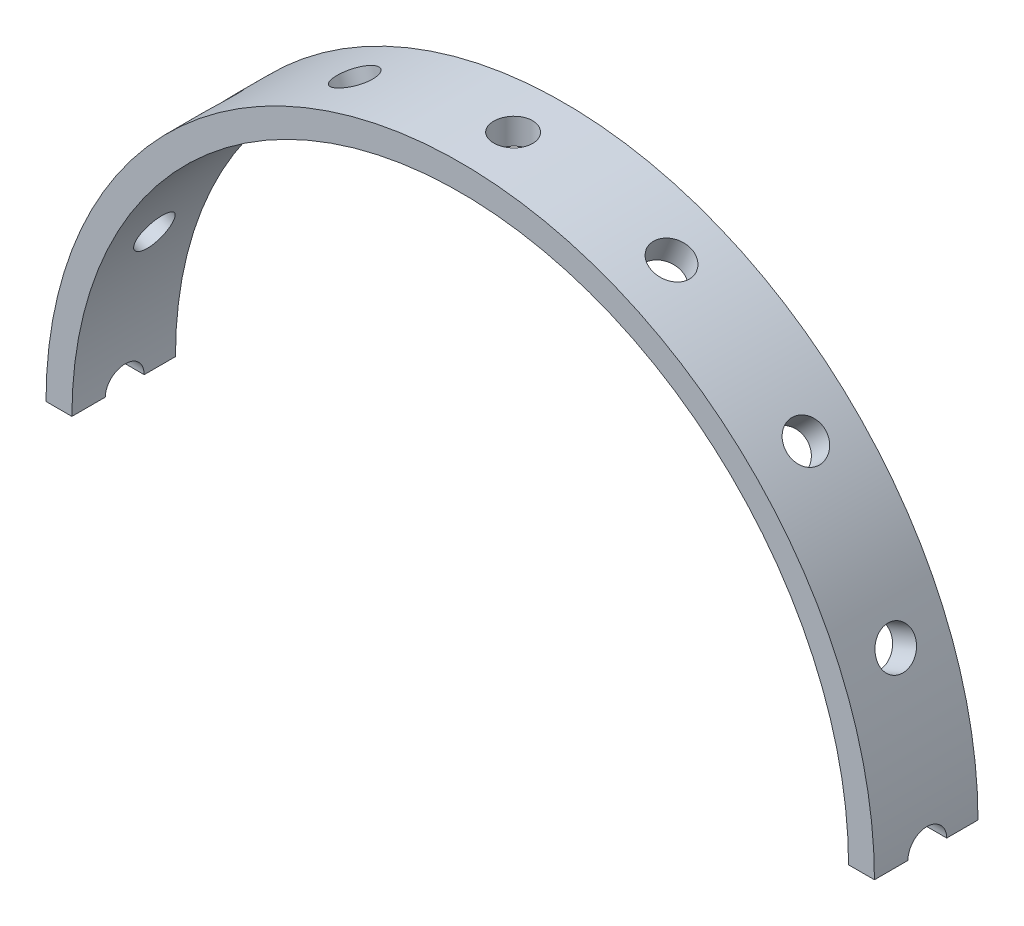
from build123d import *

# Parameters (mm, degrees)
SKETCH_1_R               = 16
SKETCH_1_R_2             = 15
EXTRUDE_1_DEPTH          = 4
SKETCH_2_R               = 0.75
CUT_EXTRUDE_1_DEPTH      = 17
PATTERN_CIRCULAR_1_COUNT = 16
SKETCH_3_W               = 36.79853237
SKETCH_3_H               = 11.94610836
CUT_EXTRUDE_2_DEPTH      = 17.0000001


with BuildPart() as part:
    # ｽｹｯﾁ1 → ﾎﾞｽ - 押し出し1 (new body)
    with BuildSketch(Plane.XY):
        Circle(SKETCH_1_R)
        Circle(SKETCH_1_R_2, mode=Mode.SUBTRACT)
    extrude(amount=EXTRUDE_1_DEPTH)

    # ｽｹｯﾁ2 → ｶｯﾄ - 押し出し1 (cut, through all)
    with BuildSketch(Plane(origin=(0, 0, 0), x_dir=(1, 0, 0), z_dir=(0, 1, 0))):
        with Locations((0, -1.957637914)):
            Circle(SKETCH_2_R)
    cut_extrude_1 = extrude(amount=-CUT_EXTRUDE_1_DEPTH, mode=Mode.SUBTRACT)

    # 円形ﾊﾟﾀｰﾝ1: ｶｯﾄ - 押し出し1 ×16 about axis
    pattern_circular_1_axis = Axis((0, 0, 0), (0, 0, 1))
    for i in range(1, PATTERN_CIRCULAR_1_COUNT):
        add(cut_extrude_1.rotate(pattern_circular_1_axis, i * 360 / PATTERN_CIRCULAR_1_COUNT), mode=Mode.SUBTRACT)

    # ｽｹｯﾁ3 → ｶｯﾄ - 押し出し2 (cut, through all)
    with BuildSketch(Plane(origin=(0, 0, 0), x_dir=(1, 0, 0), z_dir=(0, 1, 0))):
        with Locations((0, -2.028241391)):
            Rectangle(SKETCH_3_W, SKETCH_3_H)
    extrude(amount=-CUT_EXTRUDE_2_DEPTH, mode=Mode.SUBTRACT)


solid = part.part
